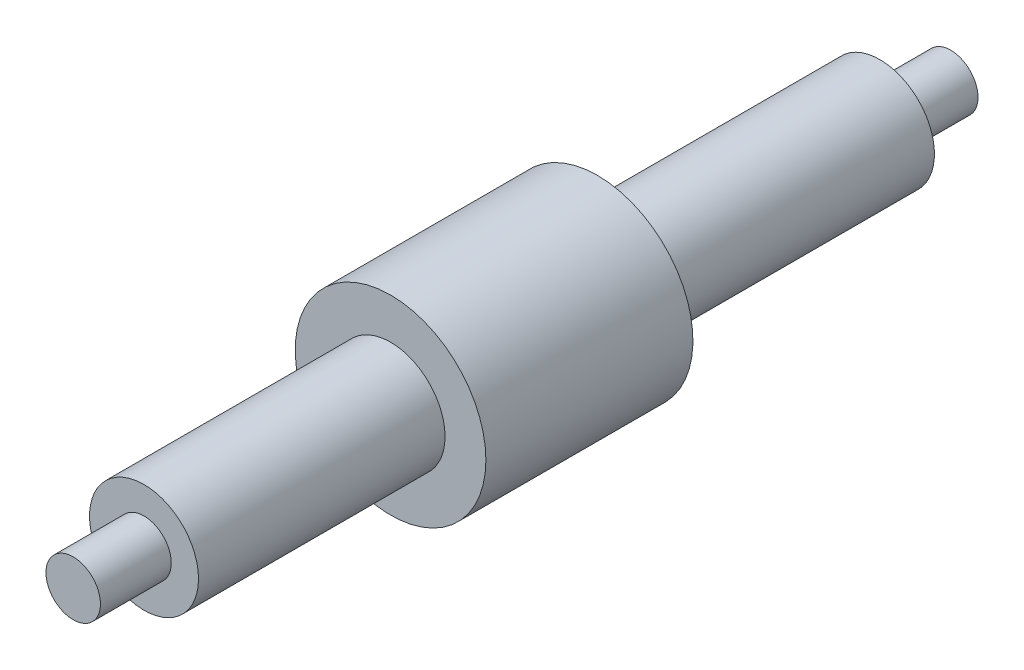
from build123d import *

# Parameters (mm, degrees)
EXTRUDE_START   = 4.80128
SKETCH_1_R      = 2
EXTRUDE_1_DEPTH = 27.013538
SKETCH_2_R      = 1
EXTRUDE_2_DEPTH = 2.6
SKETCH_4_R      = 1
EXTRUDE_3_DEPTH = 2.6
EXTRUDE_START_2 = -17.963538
SKETCH_6_R      = 3.5
EXTRUDE_5_DEPTH = 7.6


with BuildPart() as part:
    # Эскиз1 → Бобышка-Вытянуть1 (new body)
    with BuildSketch(Plane.XY.offset(EXTRUDE_START)):
        Circle(SKETCH_1_R)
    extrude(amount=EXTRUDE_1_DEPTH)

    # Эскиз2 → Бобышка-Вытянуть2 (add)
    with BuildSketch(Plane.XY.offset(31.814817835)):
        Circle(SKETCH_2_R)
    extrude(amount=EXTRUDE_2_DEPTH)

    # Эскиз4 → Бобышка-Вытянуть3 (add)
    with BuildSketch(Plane(origin=(0, 0, 4.801280123), x_dir=(-1, 0, 0), z_dir=(0, 0, -1))):
        Circle(SKETCH_4_R)
    extrude(amount=EXTRUDE_3_DEPTH)

    # Эскиз6 → Бобышка-Вытянуть5 (add)
    with BuildSketch(Plane(origin=(0, 0, 4.801280123), x_dir=(-1, 0, 0), z_dir=(0, 0, -1)).offset(EXTRUDE_START_2)):
        Circle(SKETCH_6_R)
    extrude(amount=EXTRUDE_5_DEPTH)


solid = part.part
